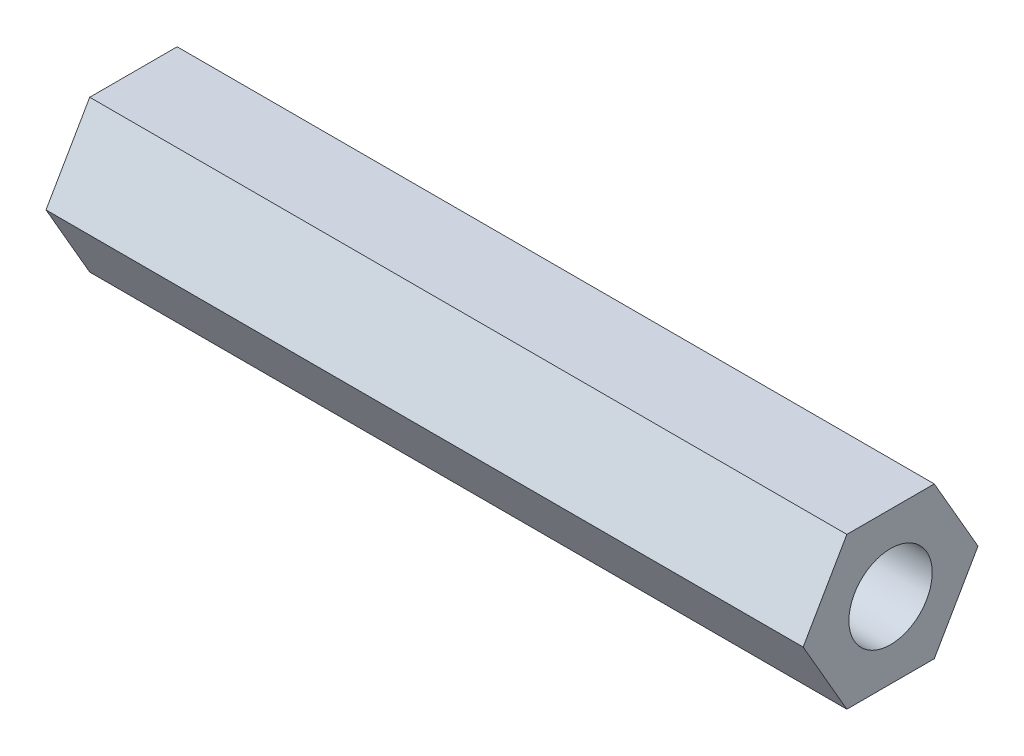
from build123d import *

# Parameters (mm, degrees)
EXTRUDE_1_DEPTH    = 30
HOLE_WIZARD_M4_1_D = 3.3


with BuildPart() as part:
    # 草图1 → 凸台-拉伸1 (new body)
    with BuildSketch(Plane(origin=(0, 0, 0), x_dir=(0, 0, -1), z_dir=(1, 0, 0))):
        Polygon((3.464101615, 0), (1.732050808, 3), (-1.732050808, 3), (-3.464101615, 0), (-1.732050808, -3), (1.732050808, -3), align=None)
    extrude(amount=EXTRUDE_1_DEPTH)

    # M4 螺纹孔1 (through all)
    with Locations(Plane.ZY):
        with Locations((0, 0)):
            Hole(HOLE_WIZARD_M4_1_D / 2)


solid = part.part
